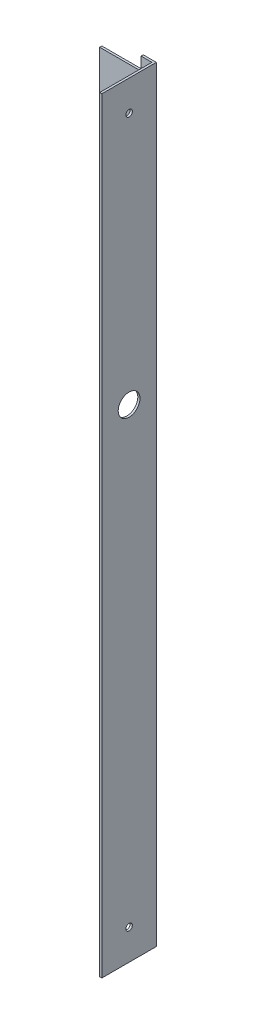
from build123d import *

# Parameters (mm, degrees)
CROQUIS2_W              = 1
CROQUIS2_H              = 352
SALIENTE_EXTRUIR2_DEPTH = 25
CROQUIS5_R              = 1.5
CROQUIS5_R_2            = 5
CORTAR_EXTRUIR2_DEPTH   = 1
SALIENTE_EXTRUIR3_DEPTH = 1


with BuildPart() as part:
    # Croquis2 → Saliente-Extruir2 (new body)
    with BuildSketch(Plane.XY):
        with Locations((-55.840004841, -113.819624774)):
            Rectangle(CROQUIS2_W, CROQUIS2_H)
    extrude(amount=SALIENTE_EXTRUIR2_DEPTH)

    # Croquis5 → Cortar-Extruir2 (cut)
    with BuildSketch(Plane(origin=(-55.340004841, 0, 0), x_dir=(0, 0, -1), z_dir=(1, 0, 0))):
        with Locations((-12.5, 48.180375226)):
            Circle(CROQUIS5_R)
        with Locations((-12.5, -275.819624774)):
            Circle(CROQUIS5_R)
        with Locations((-12.5, -67.819624774)):
            Circle(CROQUIS5_R_2)
    extrude(amount=-CORTAR_EXTRUIR2_DEPTH, mode=Mode.SUBTRACT)

    # Croquis1 → Saliente-Extruir3 (add)
    with BuildSketch(Plane.XY):
        Polygon((-56.340004841, 62.180375226), (-61.340004841, 62.180375226), (-61.340004841, 56.180375226), (-80.340004841, 56.180375226), (-80.340004841, -13.819624774), (-61.340004841, -13.819624774), (-61.340004841, -213.819624774), (-80.340004841, -213.819624774), (-80.340004841, -283.819624774), (-61.340004841, -283.819624774), (-61.340004841, -289.819624774), (-56.340004841, -289.819624774), align=None)
    extrude(amount=SALIENTE_EXTRUIR3_DEPTH)


solid = part.part
